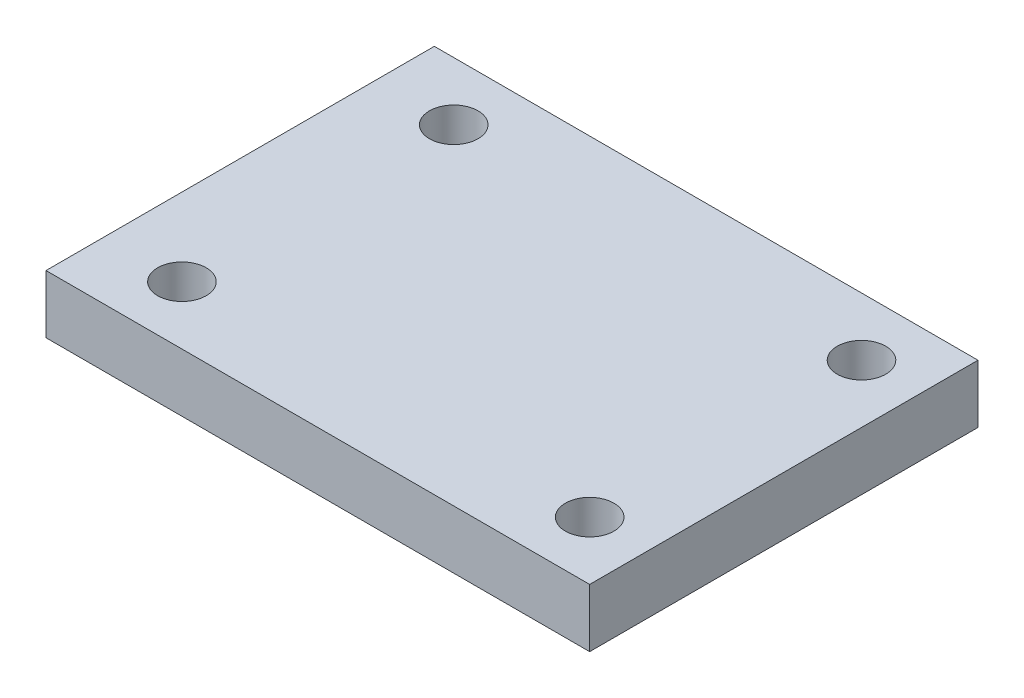
from build123d import *

# Parameters (mm, degrees)
SKETCH1_W           = 28
SKETCH1_H           = 20
BOSS_EXTRUDE1_DEPTH = 3
M3_TAPPED_HOLE1_D   = 2.5


with BuildPart() as part:
    # Sketch1 → Boss-Extrude1 (new body)
    with BuildSketch(Plane(origin=(0, 0, 0), x_dir=(1, 0, 0), z_dir=(0, 1, 0))):
        Rectangle(SKETCH1_W, SKETCH1_H)
    extrude(amount=BOSS_EXTRUDE1_DEPTH)

    # M3 Tapped Hole1 (through all)
    with Locations(Plane(origin=(0, 0, 0), x_dir=(-1, 0, 0), z_dir=(0, -1, 0))):
        with Locations((-11, 7), (10, 7), (10, -7), (-11, -7)):
            Hole(M3_TAPPED_HOLE1_D / 2)


solid = part.part
